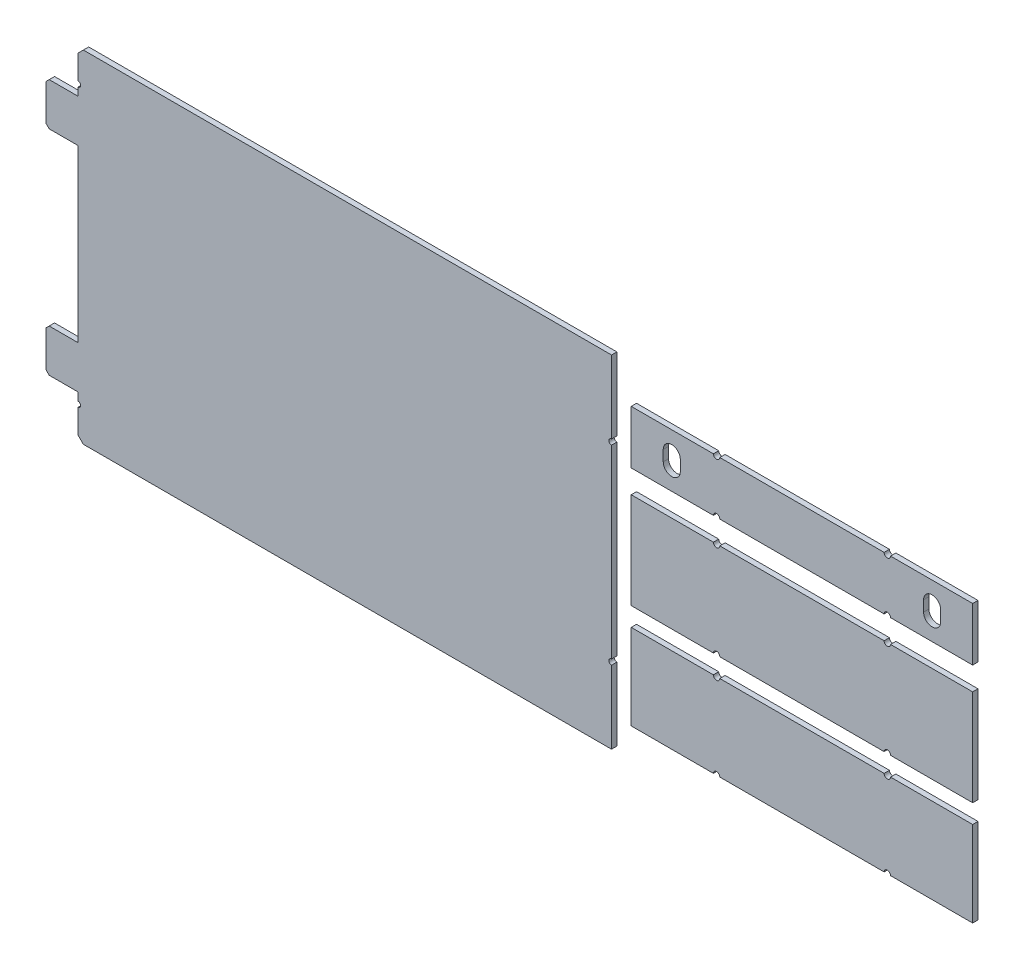
from build123d import *

# Parameters (mm, degrees)
Y_KSEKLIK_EKSTR_ZYON1_DEPTH   = 5
Y_KSEKLIK_EKSTR_ZYON1_2_DEPTH = 5
Y_KSEKLIK_EKSTR_ZYON1_3_DEPTH = 5
Y_KSEKLIK_EKSTR_ZYON1_4_DEPTH = 5


with BuildPart() as part:
    # Çizim1 → Yükseklik-Ekstrüzyon1 (new body)
    with BuildSketch(Plane.XY):
        with BuildLine():
            ThreePointArc((2022.451963564, 1497.253325842), (2024.951963564, 1499.753325842), (2022.451963564, 1502.253325842))
            Line((2022.451963564, 1502.253325842), (2022.451963564, 1509.753325842))
            Line((2022.451963564, 1509.753325842), (1995.451963564, 1509.753325842))
            Line((1995.451963564, 1509.753325842), (1992.451963564, 1512.753325842))
            Line((1992.451963564, 1512.753325842), (1992.451963564, 1546.753325842))
            Line((1992.451963564, 1546.753325842), (1995.451963564, 1549.753325842))
            Line((1995.451963564, 1549.753325842), (2022.451963564, 1549.753325842))
            Line((2022.451963564, 1549.753325842), (2022.451963564, 1709.753325842))
            Line((2022.451963564, 1709.753325842), (1995.451963564, 1709.753325842))
            Line((1995.451963564, 1709.753325842), (1992.451963564, 1712.753325842))
            Line((1992.451963564, 1712.753325842), (1992.451963564, 1746.753325842))
            Line((1992.451963564, 1746.753325842), (1995.451963564, 1749.753325842))
            Line((1995.451963564, 1749.753325842), (2022.451963564, 1749.753325842))
            Line((2022.451963564, 1749.753325842), (2022.451963564, 1757.253325842))
            ThreePointArc((2022.451963564, 1757.253325842), (2024.951963564, 1759.753325842), (2022.451963564, 1762.253325842))
            Line((2022.451963564, 1762.253325842), (2022.451963564, 1784.753325842))
            Line((2022.451963564, 1784.753325842), (2027.451963564, 1789.753325842))
            Line((2027.451963564, 1789.753325842), (2522.451963564, 1789.753325842))
            Line((2522.451963564, 1789.753325842), (2522.451963564, 1721.539040128))
            ThreePointArc((2522.451963564, 1721.539040128), (2519.951963564, 1719.039040128), (2522.451963564, 1716.539040128))
            Line((2522.451963564, 1716.539040128), (2522.451963564, 1542.967611556))
            ThreePointArc((2522.451963564, 1542.967611556), (2519.951963564, 1540.467611556), (2522.451963564, 1537.967611556))
            Line((2522.451963564, 1537.967611556), (2522.451963564, 1469.753325842))
            Line((2522.451963564, 1469.753325842), (2027.451963564, 1469.753325842))
            Line((2027.451963564, 1469.753325842), (2022.451963564, 1474.753325842))
            Line((2022.451963564, 1474.753325842), (2022.451963564, 1497.253325842))
        make_face()
    extrude(amount=Y_KSEKLIK_EKSTR_ZYON1_DEPTH)


with BuildPart() as body_2:
    # Çizim1 → Y_kseklik-Ekstr_zyon1 2 (new body)
    with BuildSketch(Plane.XY):
        with BuildLine():
            ThreePointArc((2777.91128682, 1757.275271925), (2780.91128682, 1754.275271925), (2783.91128682, 1757.275271925))
            Line((2783.91128682, 1757.275271925), (2860.91128682, 1757.275271925))
            Line((2860.91128682, 1757.275271925), (2860.91128682, 1707.275271925))
            Line((2860.91128682, 1707.275271925), (2783.91128682, 1707.275271925))
            ThreePointArc((2783.91128682, 1707.275271925), (2780.91128682, 1710.275271925), (2777.91128682, 1707.275271925))
            Line((2777.91128682, 1707.275271925), (2623.91128682, 1707.275271925))
            ThreePointArc((2623.91128682, 1707.275271925), (2620.91128682, 1710.275271925), (2617.91128682, 1707.275271925))
            Line((2617.91128682, 1707.275271925), (2540.91128682, 1707.275271925))
            Line((2540.91128682, 1707.275271925), (2540.91128682, 1757.275271925))
            Line((2540.91128682, 1757.275271925), (2617.91128682, 1757.275271925))
            ThreePointArc((2617.91128682, 1757.275271925), (2620.91128682, 1754.275271925), (2623.91128682, 1757.275271925))
            Line((2623.91128682, 1757.275271925), (2777.91128682, 1757.275271925))
        make_face()
        with BuildLine():
            ThreePointArc((2814.91128682, 1727.275271925), (2822.91128682, 1719.275271925), (2830.91128682, 1727.275271925))
            Line((2830.91128682, 1727.275271925), (2830.91128682, 1737.275271925))
            ThreePointArc((2830.91128682, 1737.275271925), (2822.91128682, 1745.275271925), (2814.91128682, 1737.275271925))
            Line((2814.91128682, 1737.275271925), (2814.91128682, 1727.275271925))
        make_face(mode=Mode.SUBTRACT)
        with BuildLine():
            ThreePointArc((2570.91128682, 1727.275271925), (2578.91128682, 1719.275271925), (2586.91128682, 1727.275271925))
            Line((2586.91128682, 1727.275271925), (2586.91128682, 1737.275271925))
            ThreePointArc((2586.91128682, 1737.275271925), (2578.91128682, 1745.275271925), (2570.91128682, 1737.275271925))
            Line((2570.91128682, 1737.275271925), (2570.91128682, 1727.275271925))
        make_face(mode=Mode.SUBTRACT)
    extrude(amount=Y_KSEKLIK_EKSTR_ZYON1_2_DEPTH)


with BuildPart() as body_3:
    # Çizim1 → Y_kseklik-Ekstr_zyon1 3 (new body)
    with BuildSketch(Plane.XY):
        with BuildLine():
            ThreePointArc((2777.91128682, 1685.543295226), (2780.91128682, 1682.543295226), (2783.91128682, 1685.543295226))
            Line((2783.91128682, 1685.543295226), (2860.91128682, 1685.543295226))
            Line((2860.91128682, 1685.543295226), (2860.91128682, 1595.543295226))
            Line((2860.91128682, 1595.543295226), (2783.91128682, 1595.543295226))
            ThreePointArc((2783.91128682, 1595.543295226), (2780.91128682, 1598.543295226), (2777.91128682, 1595.543295226))
            Line((2777.91128682, 1595.543295226), (2623.91128682, 1595.543295226))
            ThreePointArc((2623.91128682, 1595.543295226), (2620.91128682, 1598.543295226), (2617.91128682, 1595.543295226))
            Line((2617.91128682, 1595.543295226), (2540.91128682, 1595.543295226))
            Line((2540.91128682, 1595.543295226), (2540.91128682, 1685.543295226))
            Line((2540.91128682, 1685.543295226), (2617.91128682, 1685.543295226))
            ThreePointArc((2617.91128682, 1685.543295226), (2620.91128682, 1682.543295226), (2623.91128682, 1685.543295226))
            Line((2623.91128682, 1685.543295226), (2777.91128682, 1685.543295226))
        make_face()
    extrude(amount=Y_KSEKLIK_EKSTR_ZYON1_3_DEPTH)


with BuildPart() as body_4:
    # Çizim1 → Y_kseklik-Ekstr_zyon1 4 (new body)
    with BuildSketch(Plane.XY):
        with BuildLine():
            ThreePointArc((2777.91128682, 1577.897609732), (2780.91128682, 1574.897609732), (2783.91128682, 1577.897609732))
            Line((2783.91128682, 1577.897609732), (2860.91128682, 1577.897609732))
            Line((2860.91128682, 1577.897609732), (2860.91128682, 1497.897609732))
            Line((2860.91128682, 1497.897609732), (2783.91128682, 1497.897609732))
            ThreePointArc((2783.91128682, 1497.897609732), (2780.91128682, 1500.897609732), (2777.91128682, 1497.897609732))
            Line((2777.91128682, 1497.897609732), (2623.91128682, 1497.897609732))
            ThreePointArc((2623.91128682, 1497.897609732), (2620.91128682, 1500.897609732), (2617.91128682, 1497.897609732))
            Line((2617.91128682, 1497.897609732), (2540.91128682, 1497.897609732))
            Line((2540.91128682, 1497.897609732), (2540.91128682, 1577.897609732))
            Line((2540.91128682, 1577.897609732), (2617.91128682, 1577.897609732))
            ThreePointArc((2617.91128682, 1577.897609732), (2620.91128682, 1574.897609732), (2623.91128682, 1577.897609732))
            Line((2623.91128682, 1577.897609732), (2777.91128682, 1577.897609732))
        make_face()
    extrude(amount=Y_KSEKLIK_EKSTR_ZYON1_4_DEPTH)


solid = Compound([part.part, body_2.part, body_3.part, body_4.part])
